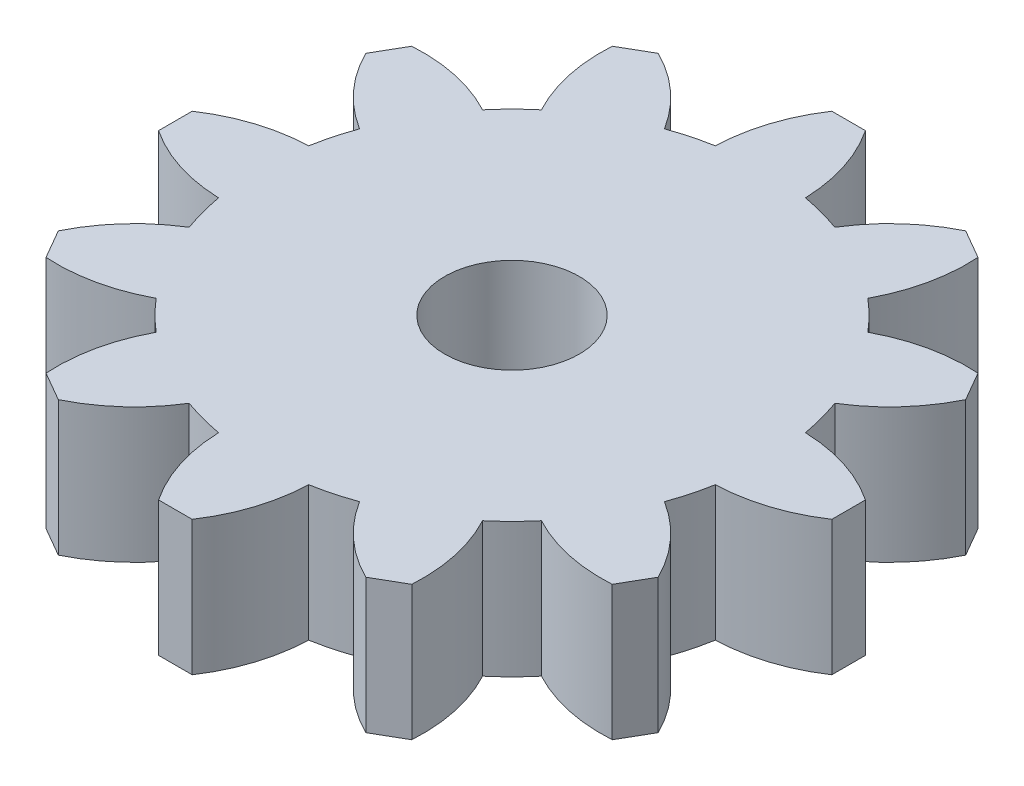
from build123d import *

# Parameters (mm, degrees)
SKETCH1_R           = 4
BOSS_EXTRUDE1_DEPTH = 4


with BuildPart() as part:
    # Sketch1 → Boss-Extrude1 (new body, symmetric)
    with BuildSketch(Plane(origin=(0, 0, 0), x_dir=(1, 0, 0), z_dir=(0, 1, 0))):
        with BuildLine():
            Line((-1, 20), (1, 20))
            ThreePointArc((1, 20), (2.204975942, 17.497232023), (2.675, 14.759551992))
            ThreePointArc((2.675, 14.759551992), (3.882285677, 14.488887394), (5.063158041, 14.119646973))
            ThreePointArc((5.063158041, 14.119646973), (6.839050831, 16.255535399), (9.133974596, 17.820508076))
            Line((9.133974596, 17.820508076), (10.866025404, 16.820508076))
            ThreePointArc((10.866025404, 16.820508076), (10.658181192, 14.050559457), (9.696393951, 11.444646973))
            ThreePointArc((9.696393951, 11.444646973), (10.606601718, 10.606601718), (11.444646973, 9.696393951))
            ThreePointArc((11.444646973, 9.696393951), (14.050559457, 10.658181192), (16.820508076, 10.866025404))
            Line((16.820508076, 10.866025404), (17.820508076, 9.133974596))
            ThreePointArc((17.820508076, 9.133974596), (16.255535399, 6.839050831), (14.119646973, 5.063158041))
            ThreePointArc((14.119646973, 5.063158041), (14.488887394, 3.882285677), (14.759551992, 2.675))
            ThreePointArc((14.759551992, 2.675), (17.497232023, 2.204975942), (20, 1))
            Line((20, 1), (20, -1))
            ThreePointArc((20, -1), (17.497232023, -2.204975942), (14.759551992, -2.675))
            ThreePointArc((14.759551992, -2.675), (14.488887394, -3.882285677), (14.119646973, -5.063158041))
            ThreePointArc((14.119646973, -5.063158041), (16.255535399, -6.839050831), (17.820508076, -9.133974596))
            Line((17.820508076, -9.133974596), (16.820508076, -10.866025404))
            ThreePointArc((16.820508076, -10.866025404), (14.050559457, -10.658181192), (11.444646973, -9.696393951))
            ThreePointArc((11.444646973, -9.696393951), (10.606601718, -10.606601718), (9.696393951, -11.444646973))
            ThreePointArc((9.696393951, -11.444646973), (10.658181192, -14.050559457), (10.866025404, -16.820508076))
            Line((10.866025404, -16.820508076), (9.133974596, -17.820508076))
            ThreePointArc((9.133974596, -17.820508076), (6.839050831, -16.255535399), (5.063158041, -14.119646973))
            ThreePointArc((5.063158041, -14.119646973), (3.882285677, -14.488887394), (2.675, -14.759551992))
            ThreePointArc((2.675, -14.759551992), (2.204975942, -17.497232023), (1, -20))
            Line((1, -20), (-1, -20))
            ThreePointArc((-1, -20), (-2.204975942, -17.497232023), (-2.675, -14.759551992))
            ThreePointArc((-2.675, -14.759551992), (-3.882285677, -14.488887394), (-5.063158041, -14.119646973))
            ThreePointArc((-5.063158041, -14.119646973), (-6.839050831, -16.255535399), (-9.133974596, -17.820508076))
            Line((-9.133974596, -17.820508076), (-10.866025404, -16.820508076))
            ThreePointArc((-10.866025404, -16.820508076), (-10.658181192, -14.050559457), (-9.696393951, -11.444646973))
            ThreePointArc((-9.696393951, -11.444646973), (-10.606601718, -10.606601718), (-11.444646973, -9.696393951))
            ThreePointArc((-11.444646973, -9.696393951), (-14.050559457, -10.658181192), (-16.820508076, -10.866025404))
            Line((-16.820508076, -10.866025404), (-17.820508076, -9.133974596))
            ThreePointArc((-17.820508076, -9.133974596), (-16.255535399, -6.839050831), (-14.119646973, -5.063158041))
            ThreePointArc((-14.119646973, -5.063158041), (-14.488887394, -3.882285677), (-14.759551992, -2.675))
            ThreePointArc((-14.759551992, -2.675), (-17.497232023, -2.204975942), (-20, -1))
            Line((-20, -1), (-20, 1))
            ThreePointArc((-20, 1), (-17.497232023, 2.204975942), (-14.759551992, 2.675))
            ThreePointArc((-14.759551992, 2.675), (-14.488887394, 3.882285677), (-14.119646973, 5.063158041))
            ThreePointArc((-14.119646973, 5.063158041), (-16.255535399, 6.839050831), (-17.820508076, 9.133974596))
            Line((-17.820508076, 9.133974596), (-16.820508076, 10.866025404))
            ThreePointArc((-16.820508076, 10.866025404), (-14.050559457, 10.658181192), (-11.444646973, 9.696393951))
            ThreePointArc((-11.444646973, 9.696393951), (-10.606601718, 10.606601718), (-9.696393951, 11.444646973))
            ThreePointArc((-9.696393951, 11.444646973), (-10.658181192, 14.050559457), (-10.866025404, 16.820508076))
            Line((-10.866025404, 16.820508076), (-9.133974596, 17.820508076))
            ThreePointArc((-9.133974596, 17.820508076), (-6.839050831, 16.255535399), (-5.063158041, 14.119646973))
            ThreePointArc((-5.063158041, 14.119646973), (-3.882285677, 14.488887394), (-2.675, 14.759551992))
            ThreePointArc((-2.675, 14.759551992), (-2.204975942, 17.497232023), (-1, 20))
        make_face()
        Circle(SKETCH1_R, mode=Mode.SUBTRACT)
    extrude(amount=BOSS_EXTRUDE1_DEPTH, both=True)


solid = part.part
